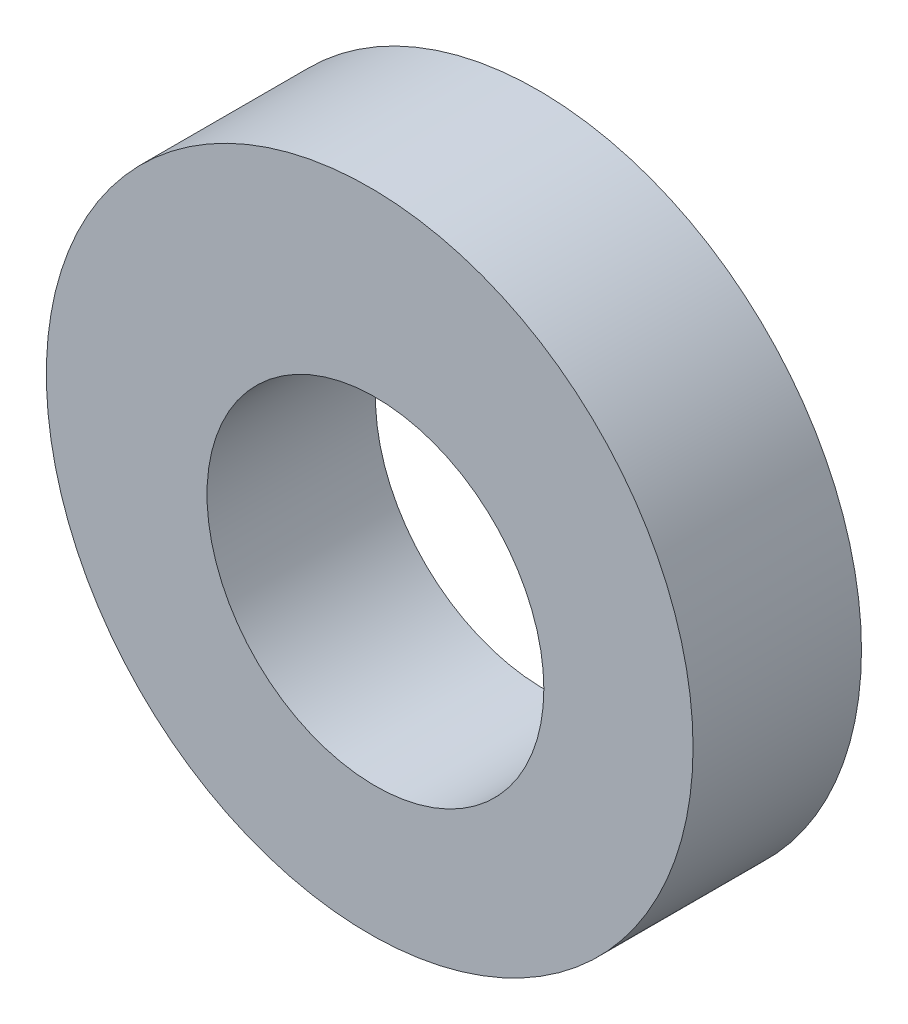
from build123d import *

# Parameters (mm, degrees)
SKETCH1_R           = 9.6
BOSS_EXTRUDE1_DEPTH = 5
SKETCH2_R           = 5
CUT_EXTRUDE1_DEPTH  = 5


with BuildPart() as part:
    # Sketch1 → Boss-Extrude1 (new body)
    with BuildSketch(Plane.XY):
        Circle(SKETCH1_R)
    extrude(amount=BOSS_EXTRUDE1_DEPTH)

    # Sketch2 → Cut-Extrude1 (cut)
    with BuildSketch(Plane.XY.offset(5)):
        with Locations((0.17, -0.71162557)):
            Circle(SKETCH2_R)
    extrude(amount=-CUT_EXTRUDE1_DEPTH, mode=Mode.SUBTRACT)


solid = part.part
